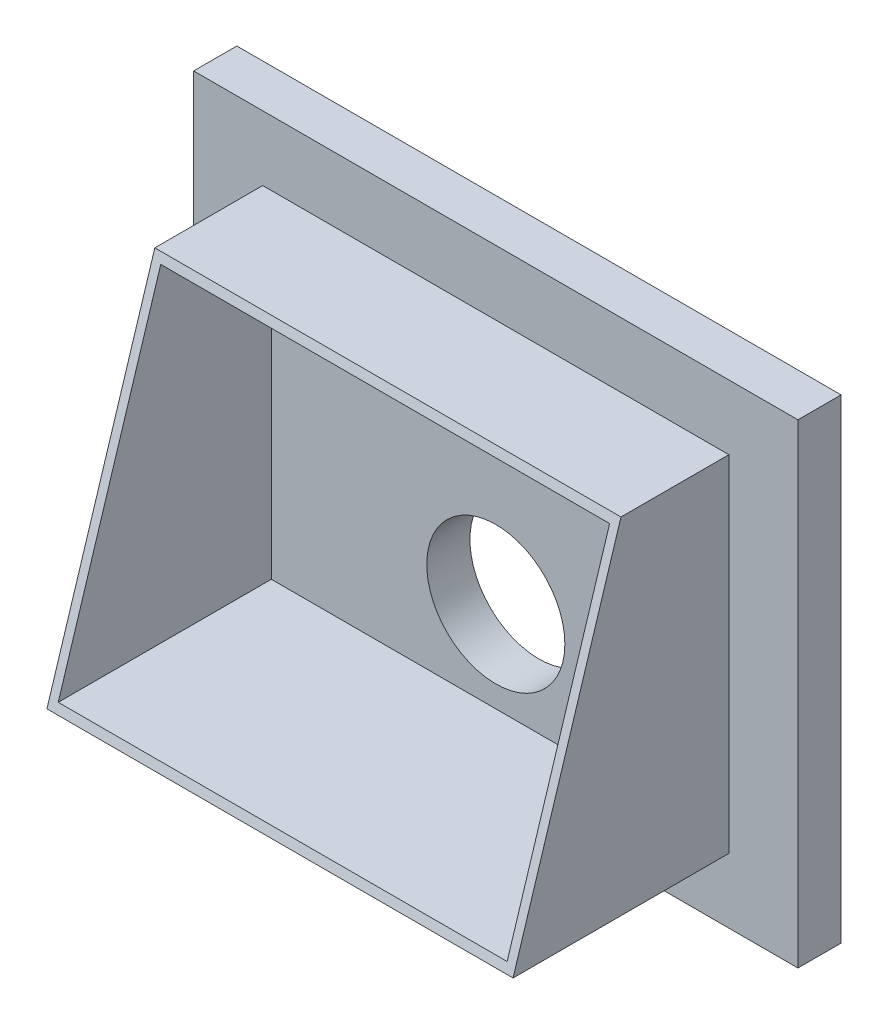
from build123d import *

# Parameters (mm, degrees)
SKETCH2_W           = 700
SKETCH2_H           = 550
BOSS_EXTRUDE1_DEPTH = 50
SKETCH3_W           = 540
SKETCH3_H           = 400
SKETCH3_W_2         = 520
SKETCH3_H_2         = 380
EXTRUDE_THIN1_DEPTH = 250
CUT_EXTRUDE1_DEPTH  = 621
SKETCH7_R           = 80
CUT_EXTRUDE2_DEPTH  = 51


with BuildPart() as part:
    # Sketch2 → Boss-Extrude1 (new body)
    with BuildSketch(Plane.XY):
        Rectangle(SKETCH2_W, SKETCH2_H)
    extrude(amount=BOSS_EXTRUDE1_DEPTH)

    # Sketch3 → Extrude-Thin1 (add)
    with BuildSketch(Plane.XY.offset(50)):
        Rectangle(SKETCH3_W, SKETCH3_H)
        Rectangle(SKETCH3_W_2, SKETCH3_H_2, mode=Mode.SUBTRACT)
    extrude(amount=EXTRUDE_THIN1_DEPTH)

    # Sketch4 → Cut-Extrude1 (cut, through all)
    with BuildSketch(Plane.ZY.offset(270)):
        Polygon((175, 200), (300, -200), (300, 200), align=None)
    extrude(amount=-CUT_EXTRUDE1_DEPTH, mode=Mode.SUBTRACT)

    # Sketch7 → Cut-Extrude2 (cut, through all)
    with BuildSketch(Plane.XY.offset(50)):
        with Locations((0, -85)):
            Circle(SKETCH7_R)
    extrude(amount=-CUT_EXTRUDE2_DEPTH, mode=Mode.SUBTRACT)


solid = part.part
